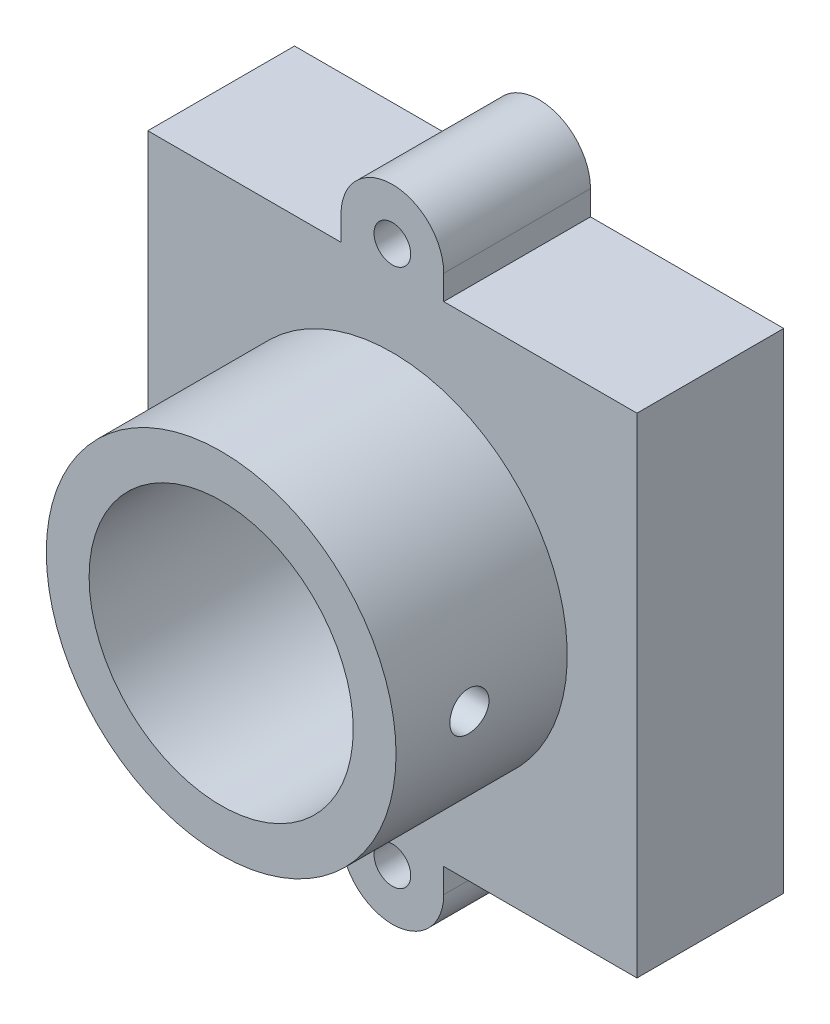
from build123d import *

# Parameters (mm, degrees)
AUFSATZ_LINEAR_AUSTRAGEN1_DEPTH        = 6
SKIZZE2_W                              = 6
SKIZZE2_H                              = 20
AUFSATZ_LINEAR_AUSTRAGEN2_DEPTH        = 7.9
SKIZZE3_W                              = 6
SKIZZE3_H                              = 20
AUFSATZ_LINEAR_AUSTRAGEN3_DEPTH        = 7.9
SKIZZE4_R                              = 7.15
AUFSATZ_LINEAR_AUSTRAGEN4_DEPTH        = 7
SKIZZE5_W                              = 19
SKIZZE5_H                              = 19
SCHNITT_LINEAR_AUSTRAGEN1_DEPTH        = 1.3
SKIZZE6_W                              = 18
SKIZZE6_H                              = 18
SCHNITT_LINEAR_AUSTRAGEN2_DEPTH        = 3.7
F_1_5_1_5_DURCHMESSER_BOHRUNG1_D       = 1.5
F_1_5_1_5_DURCHMESSER_BOHRUNG1_DEPTH   = 13
F_10_8_10_8_DURCHMESSER_BOHRUNG1_D     = 10.8
F_10_8_10_8_DURCHMESSER_BOHRUNG1_DEPTH = 13
F_1_6_1_6_DURCHMESSER_BOHRUNG1_REACH   = 25.785
F_1_6_1_6_DURCHMESSER_BOHRUNG1_BORE_R  = 0.8
FASE1_SIZE                             = 2
FASE2_SIZE                             = 2.292893219


with BuildPart() as part:
    # Skizze1 → Aufsatz-Linear austragen1 (new body)
    with BuildSketch(Plane(origin=(0, 0, 0), x_dir=(-1, 0, 0), z_dir=(0, 0, -1))):
        with BuildLine():
            Line((2.1, -11), (2.1, 11))
            ThreePointArc((2.1, 11), (0, 13.1), (-2.1, 11))
            Line((-2.1, 11), (-2.1, -11))
            ThreePointArc((-2.1, -11), (0, -13.1), (2.1, -11))
        make_face()
    extrude(amount=-AUFSATZ_LINEAR_AUSTRAGEN1_DEPTH)

    # Skizze2 → Aufsatz-Linear austragen2 (add)
    with BuildSketch(Plane.ZY.offset(2.1)):
        with Locations((3, 0)):
            Rectangle(SKIZZE2_W, SKIZZE2_H)
    extrude(amount=AUFSATZ_LINEAR_AUSTRAGEN2_DEPTH)

    # Skizze3 → Aufsatz-Linear austragen3 (add)
    with BuildSketch(Plane(origin=(2.1, 0, 0), x_dir=(0, 0, -1), z_dir=(1, 0, 0))):
        with Locations((-3, 0)):
            Rectangle(SKIZZE3_W, SKIZZE3_H)
    extrude(amount=AUFSATZ_LINEAR_AUSTRAGEN3_DEPTH)

    # Skizze4 → Aufsatz-Linear austragen4 (add)
    with BuildSketch(Plane.XY.offset(6)):
        with Locations(Location((0, 0, 0), (0, 0, 180))):
            Circle(SKIZZE4_R)
    extrude(amount=AUFSATZ_LINEAR_AUSTRAGEN4_DEPTH)

    # Skizze5 → Schnitt-Linear austragen1 (cut)
    with BuildSketch(Plane(origin=(0, 0, 0), x_dir=(-1, 0, 0), z_dir=(0, 0, -1))):
        Rectangle(SKIZZE5_W, SKIZZE5_H)
    extrude(amount=-SCHNITT_LINEAR_AUSTRAGEN1_DEPTH, mode=Mode.SUBTRACT)

    # Skizze6 → Schnitt-Linear austragen2 (cut)
    with BuildSketch(Plane(origin=(0, 0, 1.3), x_dir=(-1, 0, 0), z_dir=(0, 0, -1))):
        Rectangle(SKIZZE6_W, SKIZZE6_H)
    extrude(amount=-SCHNITT_LINEAR_AUSTRAGEN2_DEPTH, mode=Mode.SUBTRACT)

    # Ø1.5 (1.5) Durchmesser Bohrung1
    with Locations(Plane(origin=(0, 0, 0), x_dir=(-1, 0, 0), z_dir=(0, 0, -1))):
        with Locations((0, -11), (0, 11)):
            Hole(F_1_5_1_5_DURCHMESSER_BOHRUNG1_D / 2, depth=F_1_5_1_5_DURCHMESSER_BOHRUNG1_DEPTH)

    # Ø10.8 (10.8) Durchmesser Bohrung1
    with Locations(Plane.XY.offset(13)):
        with Locations((0, 0)):
            Hole(F_10_8_10_8_DURCHMESSER_BOHRUNG1_D / 2, depth=F_10_8_10_8_DURCHMESSER_BOHRUNG1_DEPTH)

    # Ø1.6 (1.6) Durchmesser Bohrung1 bore (on position points) → Ø1.6 (1.6) Durchmesser Bohrung1 (cut, up to next)
    with BuildSketch(Plane(origin=(7.15, 0, 10), x_dir=(0, 1, 0), z_dir=(1, 0, 0)), mode=Mode.PRIVATE) as f_1_6_1_6_durchmesser_bohrung1_sk1:
        Circle(F_1_6_1_6_DURCHMESSER_BOHRUNG1_BORE_R)
    f_1_6_1_6_durchmesser_bohrung1_tool1 = extrude(f_1_6_1_6_durchmesser_bohrung1_sk1.sketch, amount=-F_1_6_1_6_DURCHMESSER_BOHRUNG1_REACH, mode=Mode.PRIVATE) & part.part
    add(f_1_6_1_6_durchmesser_bohrung1_tool1.solids().sort_by_distance((7.15, 0, 10))[0], mode=Mode.SUBTRACT)

    # Fase1
    fase1_edges = [part.edges().sort_by_distance(p)[0] for p in [
        (-9, -9, 3.15),
        (9, -9, 3.15),
        (9, 9, 3.15),
        (-9, 9, 3.15),
    ]]
    chamfer(fase1_edges, length=FASE1_SIZE)

    # Fase2
    fase2_edges = [part.edges().sort_by_distance(p)[0] for p in [
        (9.5, 9.5, 0.65),
        (-9.5, 9.5, 0.65),
        (-9.5, -9.5, 0.65),
        (9.5, -9.5, 0.65),
    ]]
    chamfer(fase2_edges, length=FASE2_SIZE)


solid = part.part
